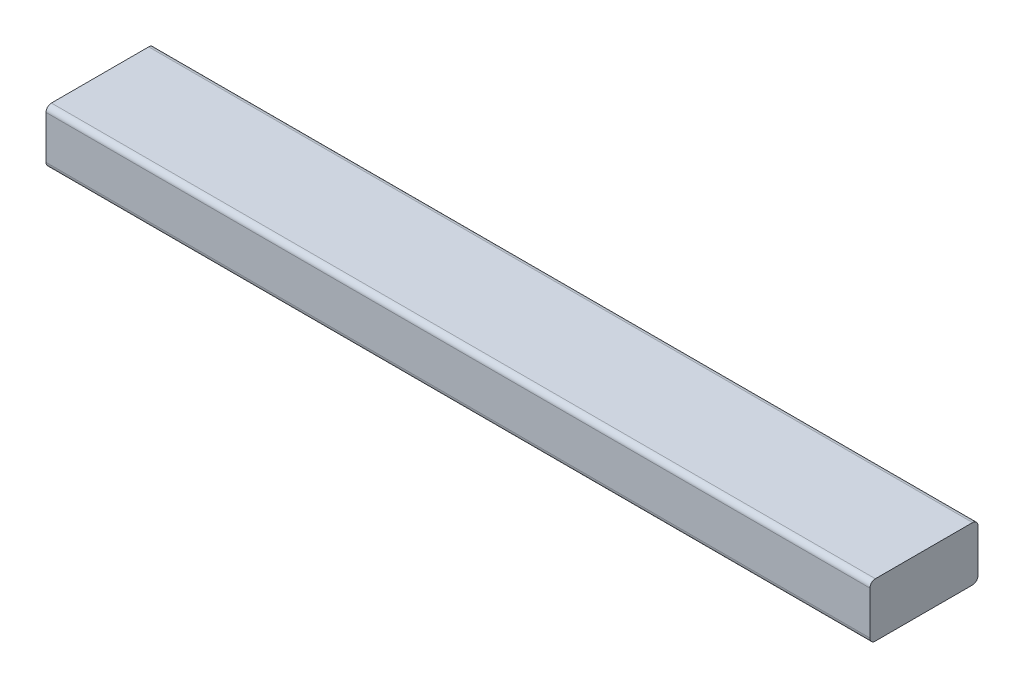
from build123d import *

# Parameters (mm, degrees)
SKETCH1_W           = 774.6
SKETCH1_H           = 101.6
BOSS_EXTRUDE1_DEPTH = 50.8
FILLET1_R           = 5.08


with BuildPart() as part:
    # Sketch1 → Boss-Extrude1 (new body)
    with BuildSketch(Plane(origin=(0, -12.7, 0), x_dir=(-1, 0, 0), z_dir=(0, -1, 0))):
        with Locations((-2200, -211.5)):
            Rectangle(SKETCH1_W, SKETCH1_H)
    extrude(amount=-BOSS_EXTRUDE1_DEPTH)

    # Fillet1
    fillet1_edges = [part.edges().sort_by_distance(p)[0] for p in [
        (2200, 38.1, 160.7),
        (2200, -12.7, 160.7),
        (2200, -12.7, 262.3),
        (2200, 38.1, 262.3),
    ]]
    fillet(fillet1_edges, radius=FILLET1_R)


solid = part.part
